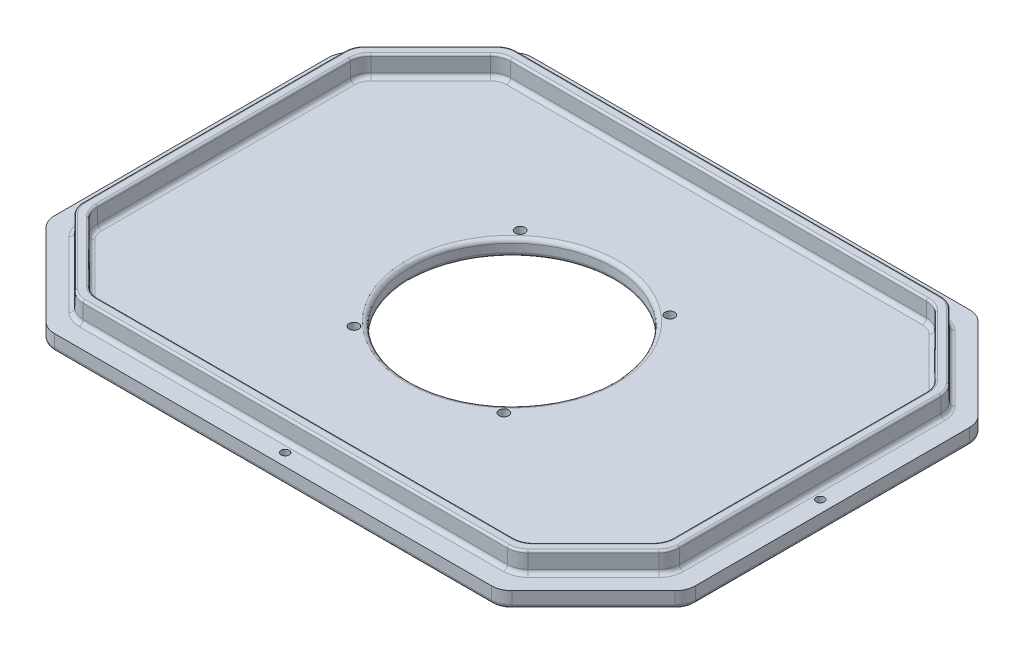
from build123d import *

# Parameters (mm, degrees)
BOSS_EXTRUDE1_DEPTH     = 4
BOSS_EXTRUDE2_DEPTH     = 10
SKETCH3_R               = 2
CUT_EXTRUDE1_DEPTH      = 197.7549237
CUT_EXTRUDE1_DEPTH_BACK = 197.7549237
SKETCH4_R               = 2.4
SKETCH4_R_2             = 50
CUT_EXTRUDE2_DEPTH      = 198.323338711
CUT_EXTRUDE2_DEPTH_BACK = 198.323338711
FILLET1_R               = 10
FILLET3_R               = 2
FILLET4_R               = 1
FILLET6_R               = 2
FILLET7_R               = 2


with BuildPart() as part:
    # Sketch1 → Boss-Extrude1 (new, symmetric)
    with BuildSketch(Plane(origin=(0, 0, 0), x_dir=(1, 0, 0), z_dir=(0, 1, 0))):
        Polygon((-111.538059223, 117.5), (111.538059223, 117.5), (157.5, 71.538059223), (157.5, -71.538059223), (111.538059223, -117.5), (-111.538059223, -117.5), (-157.5, -71.538059223), (-157.5, 71.538059223), align=None)
        Polygon((-108.395923599, -106.5), (108.395923599, -106.5), (146.5, -68.395923599), (146.5, 68.395923599), (108.395923599, 106.5), (-108.395923599, 106.5), (-146.5, 68.395923599), (-146.5, -68.395923599), align=None, mode=Mode.SUBTRACT)
        Polygon((-108.395923599, -106.5), (-146.5, -68.395923599), (-146.5, 68.395923599), (-108.395923599, 106.5), (108.395923599, 106.5), (146.5, 68.395923599), (146.5, -68.395923599), (108.395923599, -106.5), align=None)
    extrude(amount=BOSS_EXTRUDE1_DEPTH, both=True)

    # Sketch2 → Boss-Extrude2 (add)
    with BuildSketch(Plane(origin=(0, 4, 0), x_dir=(1, 0, 0), z_dir=(0, 1, 0))):
        Polygon((108.395923599, 106.5), (146.5, 68.395923599), (146.5, -68.395923599), (108.395923599, -106.5), (-108.395923599, -106.5), (-146.5, -68.395923599), (-146.5, 68.395923599), (-108.395923599, 106.5), align=None)
        Polygon((106.324855787, 101.5), (141.5, 66.324855787), (141.5, -66.324855787), (106.324855787, -101.5), (-106.324855787, -101.5), (-141.5, -66.324855787), (-141.5, 66.324855787), (-106.324855787, 101.5), align=None, mode=Mode.SUBTRACT)
    extrude(amount=BOSS_EXTRUDE2_DEPTH)

    # Sketch3 → Cut-Extrude1 (cut, two sides)
    with BuildSketch(Plane(origin=(0, 4, 0), x_dir=(1, 0, 0), z_dir=(0, 1, 0))) as cut_extrude1_sk:
        with Locations(Location((0, 111.5, 0), (0, 0, 270))):
            Circle(SKETCH3_R)
        with Locations(Location((0, -111.5, 0), (0, 0, 270))):
            Circle(SKETCH3_R)
        with Locations(Location((151.5, 0, 0), (0, 0, 270))):
            Circle(SKETCH3_R)
        with Locations(Location((-151.5, 0, 0), (0, 0, 270))):
            Circle(SKETCH3_R)
    extrude(amount=CUT_EXTRUDE1_DEPTH, mode=Mode.SUBTRACT)
    extrude(cut_extrude1_sk.sketch, amount=-CUT_EXTRUDE1_DEPTH_BACK, mode=Mode.SUBTRACT)

    # Sketch4 → Cut-Extrude2 (cut, two sides)
    with BuildSketch(Plane.XZ.offset(4)) as cut_extrude2_sk:
        with Locations(Location((-36.842001616, -40.837077723, 0), (0, 0, 270))):
            Circle(SKETCH4_R)
        with Locations(Location((36, -41.581245773, 0), (0, 0, 270))):
            Circle(SKETCH4_R)
        with Locations(Location((-36.842001616, 40.837077723, 0), (0, 0, 270))):
            Circle(SKETCH4_R)
        with Locations(Location((36.842001616, 40.837077723, 0), (0, 0, 270))):
            Circle(SKETCH4_R)
        with Locations(Location((0, 0, 0), (0, 0, 270))):
            Circle(SKETCH4_R_2)
    extrude(amount=CUT_EXTRUDE2_DEPTH, mode=Mode.SUBTRACT)
    extrude(cut_extrude2_sk.sketch, amount=-CUT_EXTRUDE2_DEPTH_BACK, mode=Mode.SUBTRACT)

    # Fillet1
    fillet1_edges = [part.edges().sort_by_distance(p)[0] for p in [
        (111.538059223, 0, -117.5),
        (157.5, 0, -71.538059223),
        (157.5, 0, 71.538059223),
        (111.538059223, 0, 117.5),
        (-111.538059223, 0, 117.5),
        (-157.5, 0, 71.538059223),
        (-157.5, 0, -71.538059223),
        (-111.538059223, 0, -117.5),
        (108.395923599, 9, -106.5),
        (-108.395923599, 9, -106.5),
        (-146.5, 9, -68.395923599),
        (-146.5, 9, 68.395923599),
        (-108.395923599, 9, 106.5),
        (108.395923599, 9, 106.5),
        (146.5, 9, 68.395923599),
        (146.5, 9, -68.395923599),
        (-106.324855787, 9, -101.5),
        (-141.5, 9, -66.324855787),
        (-141.5, 9, 66.324855787),
        (-106.324855787, 9, 101.5),
        (106.324855787, 9, 101.5),
        (141.5, 9, 66.324855787),
        (141.5, 9, -66.324855787),
        (106.324855787, 9, -101.5),
    ]]
    fillet(fillet1_edges, radius=FILLET1_R)

    # Fillet3
    fillet3_edges = [part.edges().sort_by_distance(p)[0] for p in [
        (141.5, 4, 0),
        (0, 4, -101.5),
        (-123.912427894, 4, -83.912427894),
        (-141.5, 4, 0),
        (-123.912427894, 4, 83.912427894),
        (0, 4, 101.5),
        (123.912427894, 4, 83.912427894),
        (123.912427894, 4, -83.912427894),
        (-140.738795325, 4, -66.009554487),
        (-106.009554487, 4, -100.738795325),
        (-106.009554487, 4, 100.738795325),
        (-140.738795325, 4, 66.009554487),
        (140.738795325, 4, 66.009554487),
        (106.009554487, 4, 100.738795325),
        (106.009554487, 4, -100.738795325),
        (140.738795325, 4, -66.009554487),
        (127.4479618, 4, 87.4479618),
        (0, 4, 106.5),
        (146.5, 4, 0),
        (127.4479618, 4, -87.4479618),
        (0, 4, -106.5),
        (-127.4479618, 4, -87.4479618),
        (-146.5, 4, 0),
        (-127.4479618, 4, 87.4479618),
        (108.080622299, 4, 105.738795325),
        (145.738795325, 4, 68.080622299),
        (145.738795325, 4, -68.080622299),
        (108.080622299, 4, -105.738795325),
        (-108.080622299, 4, -105.738795325),
        (-145.738795325, 4, -68.080622299),
        (-145.738795325, 4, 68.080622299),
        (-108.080622299, 4, 105.738795325),
    ]]
    fillet(fillet3_edges, radius=FILLET3_R)

    # Fillet4
    fillet4_edges = [part.edges().sort_by_distance(p)[0] for p in [
        (141.5, 14, 0),
        (123.912427894, 14, -83.912427894),
        (0, 14, -101.5),
        (0, 14, 101.5),
        (123.912427894, 14, 83.912427894),
        (-141.5, 14, 0),
        (-123.912427894, 14, 83.912427894),
        (-123.912427894, 14, -83.912427894),
        (127.4479618, 14, 87.4479618),
        (0, 14, 106.5),
        (0, 14, -106.5),
        (-127.4479618, 14, -87.4479618),
        (-146.5, 14, 0),
        (-127.4479618, 14, 87.4479618),
        (146.5, 14, 0),
        (127.4479618, 14, -87.4479618),
        (-108.080622299, 14, 105.738795325),
        (-145.738795325, 14, 68.080622299),
        (-145.738795325, 14, -68.080622299),
        (-108.080622299, 14, -105.738795325),
        (108.080622299, 14, -105.738795325),
        (145.738795325, 14, -68.080622299),
        (145.738795325, 14, 68.080622299),
        (108.080622299, 14, 105.738795325),
        (140.738795325, 14, -66.009554487),
        (106.009554487, 14, -100.738795325),
        (106.009554487, 14, 100.738795325),
        (140.738795325, 14, 66.009554487),
        (-140.738795325, 14, 66.009554487),
        (-106.009554487, 14, 100.738795325),
        (-106.009554487, 14, -100.738795325),
        (-140.738795325, 14, -66.009554487),
    ]]
    fillet(fillet4_edges, radius=FILLET4_R)

    # Fillet6
    fillet6_edges = [part.edges().sort_by_distance(p)[0] for p in [
        (134.519029611, -4, 94.519029611),
        (0, -4, -117.5),
        (134.519029611, -4, -94.519029611),
        (157.5, -4, 0),
        (0, -4, 117.5),
        (-134.519029611, -4, 94.519029611),
        (-157.5, -4, 0),
        (-134.519029611, -4, -94.519029611),
        (111.222757923, -4, -116.738795325),
        (156.738795325, -4, -71.222757923),
        (-111.222757923, -4, -116.738795325),
        (-156.738795325, -4, -71.222757923),
        (-156.738795325, -4, 71.222757923),
        (-111.222757923, -4, 116.738795325),
        (156.738795325, -4, 71.222757923),
        (111.222757923, -4, 116.738795325),
    ]]
    fillet(fillet6_edges, radius=FILLET6_R)

    # Fillet7
    fillet7_edges = [part.edges().sort_by_distance(p)[0] for p in [
        (0, 4, 50),
        (0, -4, 50),
    ]]
    fillet(fillet7_edges, radius=FILLET7_R)


solid = part.part
